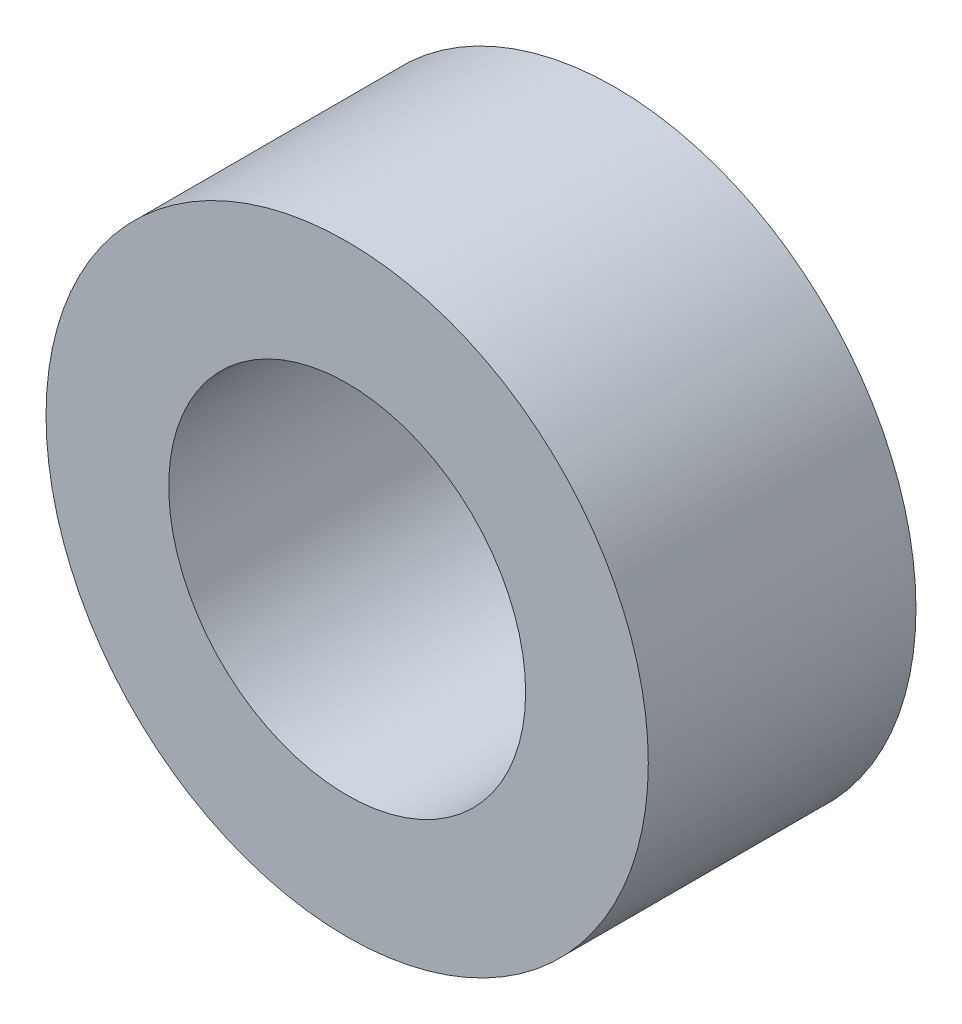
from build123d import *

# Parameters (mm, degrees)
CROQUIS1_R              = 94.5
SALIENTE_EXTRUIR1_DEPTH = 84
CROQUIS2_R              = 56
CORTAR_EXTRUIR1_DEPTH   = 84


with BuildPart() as part:
    # Croquis1 → Saliente-Extruir1 (new body)
    with BuildSketch(Plane.XY):
        Circle(CROQUIS1_R)
    extrude(amount=SALIENTE_EXTRUIR1_DEPTH)

    # Croquis2 → Cortar-Extruir1 (cut)
    with BuildSketch(Plane.XY.offset(84)):
        Circle(CROQUIS2_R)
    extrude(amount=-CORTAR_EXTRUIR1_DEPTH, mode=Mode.SUBTRACT)


solid = part.part
